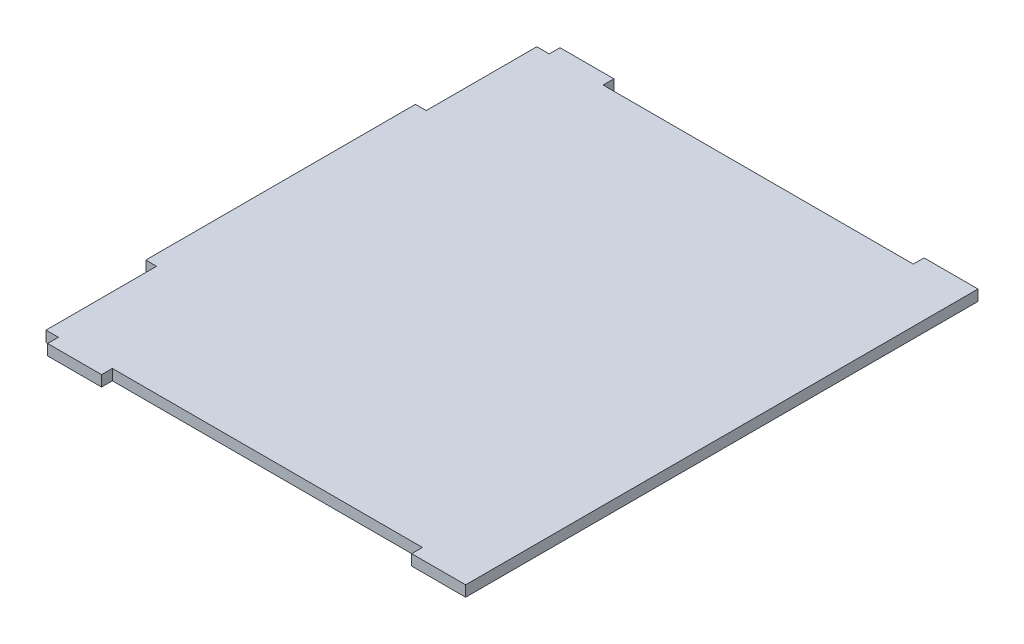
from build123d import *

# Parameters (mm, degrees)
BOSS_EXTRUDE1_DEPTH = 4


with BuildPart() as part:
    # Sketch1 → Boss-Extrude1 (new body)
    with BuildSketch(Plane(origin=(0, 0, 0), x_dir=(1, 0, 0), z_dir=(0, 1, 0))):
        Polygon((-77.805, -91), (-73.199270762, -91), (-73.199270762, -95), (-53.199270762, -95), (-53.199270762, -91), (61.800729238, -91), (61.800729238, -95), (81.805, -95), (81.805, 95), (61.800729238, 95), (61.800729238, 91), (-53.199270762, 91), (-53.199270762, 95), (-73.199270762, 95), (-73.199270762, 91), (-77.805, 91), (-77.805, 50), (-81.805, 50), (-81.805, -50), (-77.805, -50), align=None)
    extrude(amount=BOSS_EXTRUDE1_DEPTH)


solid = part.part
